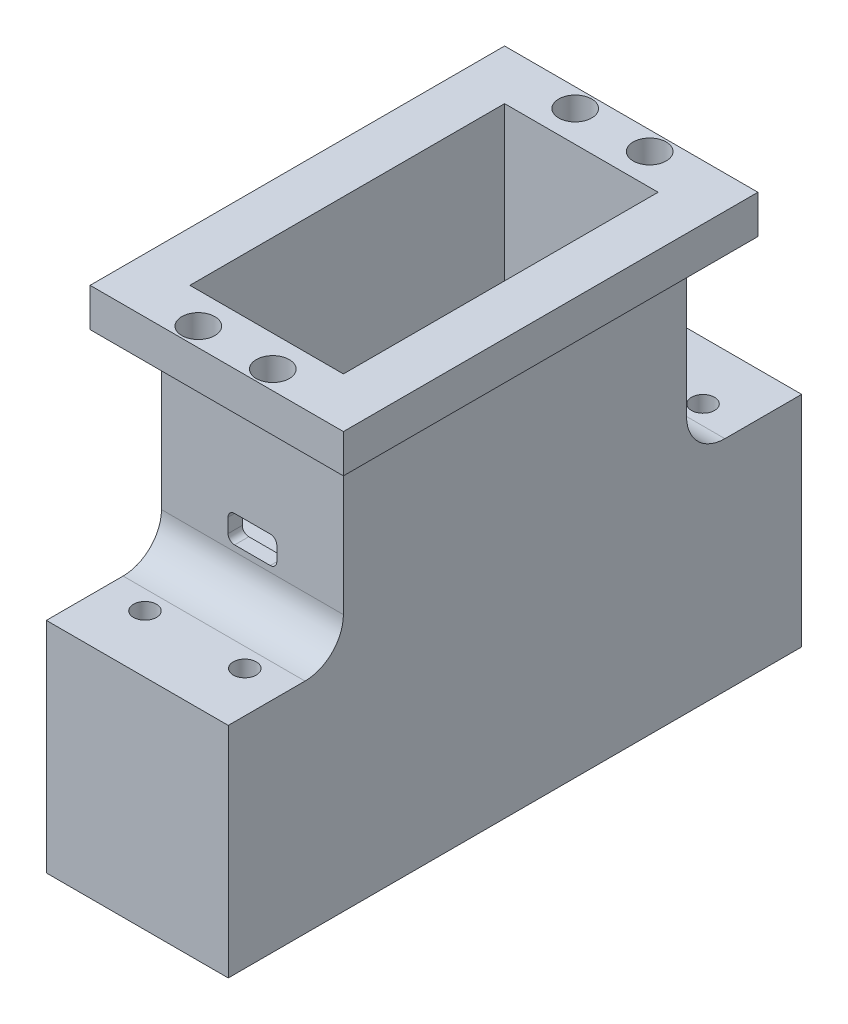
from build123d import *

# Parameters (mm, degrees)
CROQUIS1_W              = 23.7
CROQUIS1_H              = 44.7
CROQUIS1_W_2            = 20
CROQUIS1_H_2            = 41
SALIENTE_EXTRUIR1_DEPTH = 30.3
CROQUIS1_2_W            = 20
CROQUIS1_2_H            = 41
SALIENTE_EXTRUIR2_DEPTH = 2
SALIENTE_EXTRUIR3_START = 30.3
CROQUIS1_4_W            = 33
CROQUIS1_4_H            = 54
CROQUIS1_4_W_2          = 23.7
CROQUIS1_4_H_2          = 44.7
SALIENTE_EXTRUIR3_DEPTH = 5
CROQUIS2_W              = 23.7
CROQUIS2_H              = 74.7
CROQUIS2_R              = 1.5
SALIENTE_EXTRUIR5_DEPTH = 28.5
REDONDEO2_R             = 5
CORTAR_EXTRUIR1_DEPTH   = 5
CROQUIS4_R              = 2.15
CORTAR_EXTRUIR2_DEPTH   = 10


with BuildPart() as part:
    # Croquis1 → Saliente-Extruir1 (new body)
    with BuildSketch(Plane(origin=(0, 0, 0), x_dir=(1, 0, 0), z_dir=(0, 1, 0))):
        Rectangle(CROQUIS1_W, CROQUIS1_H)
        Rectangle(CROQUIS1_W_2, CROQUIS1_H_2, mode=Mode.SUBTRACT)
    extrude(amount=SALIENTE_EXTRUIR1_DEPTH)

    # Croquis1_2 → Saliente-Extruir2 (add)
    with BuildSketch(Plane(origin=(0, 0, 0), x_dir=(1, 0, 0), z_dir=(0, 1, 0))):
        Rectangle(CROQUIS1_2_W, CROQUIS1_2_H)
    extrude(amount=SALIENTE_EXTRUIR2_DEPTH)

    # Croquis1_4 → Saliente-Extruir3 (add)
    with BuildSketch(Plane(origin=(0, 0, 0), x_dir=(1, 0, 0), z_dir=(0, 1, 0)).offset(SALIENTE_EXTRUIR3_START)):
        Rectangle(CROQUIS1_4_W, CROQUIS1_4_H)
        Rectangle(CROQUIS1_4_W_2, CROQUIS1_4_H_2, mode=Mode.SUBTRACT)
    extrude(amount=-SALIENTE_EXTRUIR3_DEPTH)

    # Croquis2 → Saliente-Extruir5 (add)
    with BuildSketch(Plane.XZ):
        Rectangle(CROQUIS2_W, CROQUIS2_H)
        with Locations((-6.5, 29.85)):
            Circle(CROQUIS2_R, mode=Mode.SUBTRACT)
        with Locations((6.5, 29.85)):
            Circle(CROQUIS2_R, mode=Mode.SUBTRACT)
        with Locations((6.5, -29.85)):
            Circle(CROQUIS2_R, mode=Mode.SUBTRACT)
        with Locations((-6.5, -29.85)):
            Circle(CROQUIS2_R, mode=Mode.SUBTRACT)
    extrude(amount=SALIENTE_EXTRUIR5_DEPTH)

    # Redondeo2
    redondeo2_edges = [part.edges().sort_by_distance(p)[0] for p in [
        (0, 0, 22.35),
        (0, 0, -22.35),
    ]]
    fillet(redondeo2_edges, radius=REDONDEO2_R)

    # Croquis3 → Cortar-Extruir1 (cut, symmetric)
    with BuildSketch(Plane.XY.offset(22.35)):
        with BuildLine():
            Line((-2.325, 9.325), (2.325, 9.325))
            ThreePointArc((2.325, 9.325), (2.926040764, 9.076040764), (3.175, 8.475))
            Line((3.175, 8.475), (3.175, 6.625))
            ThreePointArc((3.175, 6.625), (2.926040764, 6.023959236), (2.325, 5.775))
            Line((2.325, 5.775), (-2.325, 5.775))
            ThreePointArc((-2.325, 5.775), (-2.926040764, 6.023959236), (-3.175, 6.625))
            Line((-3.175, 6.625), (-3.175, 8.475))
            ThreePointArc((-3.175, 8.475), (-2.926040764, 9.076040764), (-2.325, 9.325))
        make_face()
    extrude(amount=CORTAR_EXTRUIR1_DEPTH, both=True, mode=Mode.SUBTRACT)

    # Croquis4 → Cortar-Extruir2 (cut)
    with BuildSketch(Plane(origin=(0, 30.3, 0), x_dir=(1, 0, 0), z_dir=(0, 1, 0))):
        with Locations((-4.85, 24.55)):
            Circle(CROQUIS4_R)
        with Locations((4.85, 24.55)):
            Circle(CROQUIS4_R)
        with Locations((-4.85, -24.55)):
            Circle(CROQUIS4_R)
        with Locations((4.85, -24.55)):
            Circle(CROQUIS4_R)
    extrude(amount=-CORTAR_EXTRUIR2_DEPTH, mode=Mode.SUBTRACT)


solid = part.part
